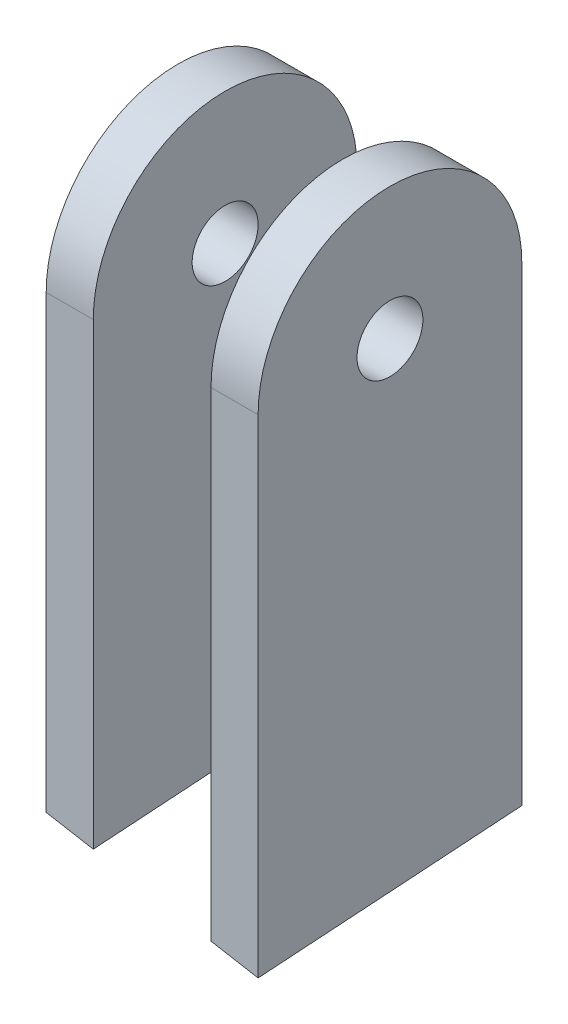
from build123d import *

# Parameters (mm, degrees)
EXTRUDE_1_DEPTH      = 10
EXTRUDE_1_DEPTH_BACK = 35
SKETCH_1_R           = 7
CUT_EXTRUDE_START    = -25
SKETCH_1_2_R         = 7
CUT_EXTRUDE_1_DEPTH  = 25
SKETCH_2_R           = 162.622084324
CUT_EXTRUDE_2_DEPTH  = 168


with BuildPart() as part:
    # 草图1 → 凸台-拉伸1 (new, two sides: drawn at the far end of the back side and taken through both)
    with BuildSketch(Plane(origin=(0, 0, 0), x_dir=(0, 0, -1), z_dir=(1, 0, 0)).offset(-EXTRUDE_1_DEPTH_BACK)):
        with BuildLine():
            Line((-28, 0), (-28, -200))
            Line((-28, -200), (28, -200))
            Line((28, -200), (28, 0))
            ThreePointArc((28, 0), (0, 28), (-28, 0))
        make_face()
        Circle(SKETCH_1_R, mode=Mode.SUBTRACT)
    extrude(amount=EXTRUDE_1_DEPTH + EXTRUDE_1_DEPTH_BACK)

    # 草图1<2> → 切除-拉伸1 (cut)
    with BuildSketch(Plane(origin=(0, 0, 0), x_dir=(0, 0, -1), z_dir=(1, 0, 0)).offset(CUT_EXTRUDE_START)):
        with BuildLine():
            Line((-28, 0), (-28, -200))
            Line((-28, -200), (28, -200))
            Line((28, -200), (28, 0))
            ThreePointArc((28, 0), (0, 28), (-28, 0))
        make_face()
        Circle(SKETCH_1_2_R, mode=Mode.SUBTRACT)
    extrude(amount=CUT_EXTRUDE_1_DEPTH, mode=Mode.SUBTRACT)


with BuildPart() as cut_extrude_1_piece_1:
    # of the separate pieces the step leaves, piece 1, a body of its own (cut_extrude_1_pieces)
    add(part.part.solids().sort_by_distance((10, 0, 28))[0])


with BuildPart() as cut_extrude_1_piece_2:
    # of the separate pieces the step leaves, piece 2, a body of its own (cut_extrude_1_pieces)
    add(part.part.solids().sort_by_distance((-25, 0, 28))[0])


with BuildPart() as cut_extrude_2_tool:
    # 草图2 → 切除-拉伸2 (new body)
    with BuildSketch(Plane(origin=(-17.060033695, -96.541924604, -6.376237343), x_dir=(-0.9498379877166935, 0.18452396761475204, -0.25250485632164077), z_dir=(0.17364817766693202, 0.9826668326704634, 0.06490151278940554))):
        Circle(SKETCH_2_R)
    extrude(amount=-CUT_EXTRUDE_2_DEPTH)


with BuildPart() as cut_extrude_1_piece_1_1:
    add(cut_extrude_1_piece_1.part)

    # 切除-拉伸2: cut by cut_extrude_2_tool
    add(cut_extrude_2_tool.part, mode=Mode.SUBTRACT)


with BuildPart() as cut_extrude_1_piece_2_1:
    add(cut_extrude_1_piece_2.part)

    # 切除-拉伸2: cut by cut_extrude_2_tool
    add(cut_extrude_2_tool.part, mode=Mode.SUBTRACT)


solid = Compound([cut_extrude_1_piece_1_1.part, cut_extrude_1_piece_2_1.part])
